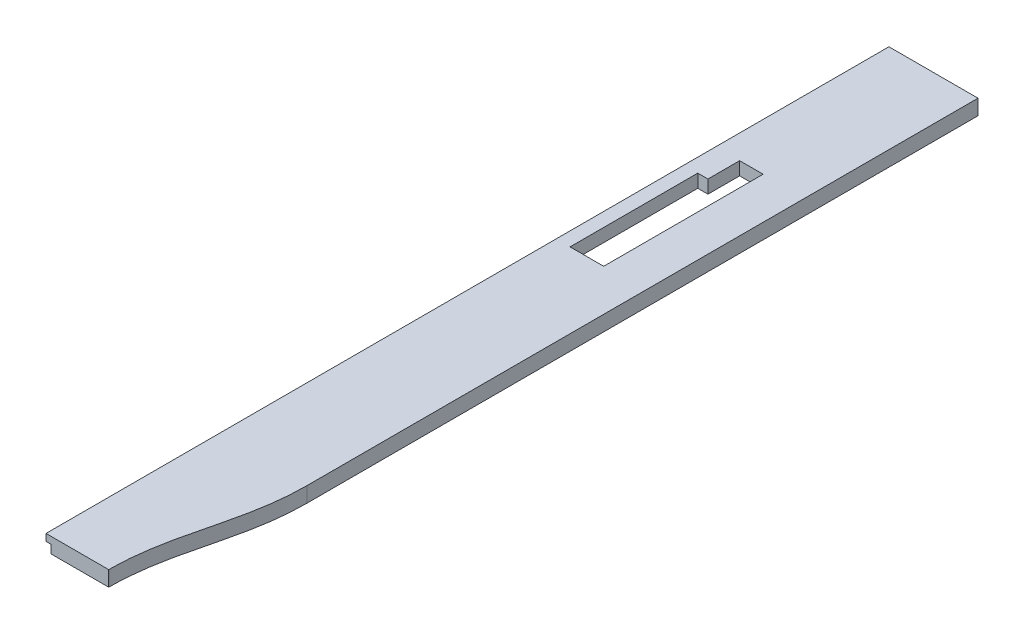
from build123d import *

# Parameters (mm, degrees)
ESQUISSE1_W             = 128.5
ESQUISSE1_H             = 22
BOSS_EXTRU_1_DEPTH      = 1216
ENL_V_MAT_EXTRU_1_DEPTH = 23
ESQUISSE5_W             = 212
ESQUISSE5_H             = 12
ENL_V_MAT_EXTRU_2_DEPTH = 7
ENL_V_MAT_EXTRU_3_DEPTH = 3
ENL_V_MAT_EXTRU_4_DEPTH = 20.0000001


with BuildPart() as part:
    # Esquisse1 → Boss.-Extru.1 (new body)
    with BuildSketch(Plane.XY):
        with Locations((64.25, -495)):
            Rectangle(ESQUISSE1_W, ESQUISSE1_H)
    extrude(amount=BOSS_EXTRU_1_DEPTH)

    # Esquisse4 → Enlèv. mat.-Extru.1 (cut, through all)
    with BuildSketch(Plane(origin=(0, -484, 0), x_dir=(1, 0, 0), z_dir=(0, 1, 0))):
        with BuildLine():
            Line((90.5, -1215.9), (90.5, -1216))
            Line((90.5, -1216), (128.5, -1216))
            Line((128.5, -1216), (128.5, -968))
            add(Edge.make_bspline(
                [(128.5, -968), (128.5, -1061.333333333), (90.5, -1122.566666667), (90.5, -1215.9)],
                knots=[0, 0, 0, 0, 1, 1, 1, 1], degree=3))
        make_face()
    extrude(amount=-ENL_V_MAT_EXTRU_1_DEPTH, mode=Mode.SUBTRACT)

    # Esquisse5 → Enlèv. mat.-Extru.2 (cut)
    with BuildSketch(Plane.ZY):
        with Locations((1110, -500)):
            Rectangle(ESQUISSE5_W, ESQUISSE5_H)
    extrude(amount=-ENL_V_MAT_EXTRU_2_DEPTH, mode=Mode.SUBTRACT)

    # Esquisse6 → Enlèv. mat.-Extru.3 (cut)
    with BuildSketch(Plane.XZ.offset(506)):
        with BuildLine():
            Line((10, 480), (10, 250))
            ThreePointArc((10, 250), (12.928932188, 242.928932188), (20, 240))
            Line((20, 240), (68.5, 240))
            ThreePointArc((68.5, 240), (75.571067812, 242.928932188), (78.5, 250))
            Line((78.5, 250), (78.5, 480))
            ThreePointArc((78.5, 480), (75.571067812, 487.071067812), (68.5, 490))
            Line((68.5, 490), (20, 490))
            ThreePointArc((20, 490), (12.928932188, 487.071067812), (10, 480))
        make_face()
    extrude(amount=-ENL_V_MAT_EXTRU_3_DEPTH, mode=Mode.SUBTRACT)

    # Esquisse11 → Enlèv. mat.-Extru.4 (cut, through all)
    with BuildSketch(Plane.XZ.offset(503)):
        Polygon((68.5, 480), (20, 480), (20, 295.75), (34.65, 295.75), (34.65, 250), (68.5, 250), align=None)
    extrude(amount=-ENL_V_MAT_EXTRU_4_DEPTH, mode=Mode.SUBTRACT)


solid = part.part
